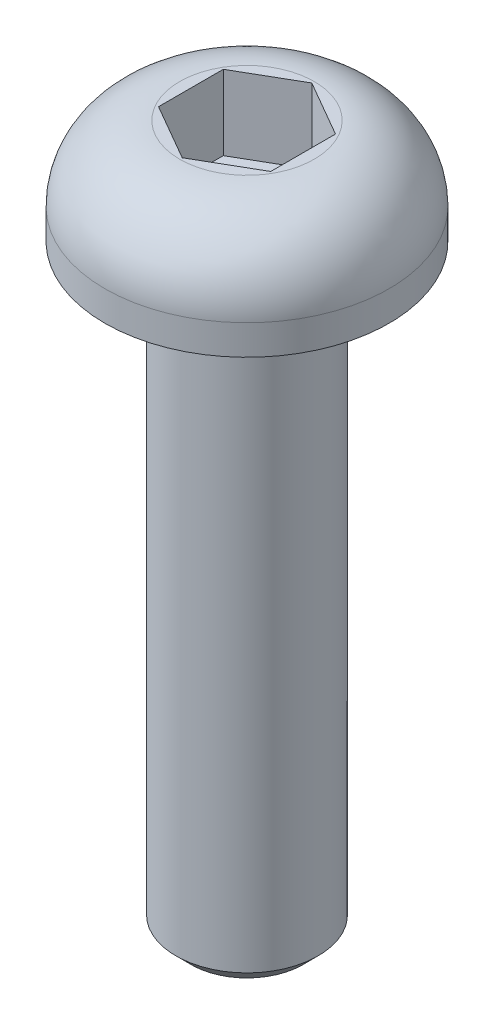
from build123d import *

# Parameters (mm, degrees)
SKETCH_1_R          = 1.9
EXTRUDE_1_DEPTH     = 1.4
CUT_EXTRUDE_1_DEPTH = 1
FILLET_1_R          = 1
SKETCH_3_R          = 0.95
EXTRUDE_2_DEPTH     = 8
CHAMFER_1_SIZE      = 0.2


with BuildPart() as part:
    # 草图1 → 凸台-拉伸1 (new body)
    with BuildSketch(Plane(origin=(0, 0, 0), x_dir=(1, 0, 0), z_dir=(0, 1, 0))):
        Circle(SKETCH_1_R)
    extrude(amount=EXTRUDE_1_DEPTH)

    # 草图2 → 切除-拉伸1 (cut)
    with BuildSketch(Plane(origin=(0, 1.4, 0), x_dir=(1, 0, 0), z_dir=(0, 1, 0))):
        Polygon((0, -0.866025404), (0.75, -0.433012702), (0.75, 0.433012702), (0, 0.866025404), (-0.75, 0.433012702), (-0.75, -0.433012702), align=None)
    extrude(amount=-CUT_EXTRUDE_1_DEPTH, mode=Mode.SUBTRACT)

    # 圆角1
    fillet_1_edges = [part.edges().sort_by_distance(p)[0] for p in [
        (-1.9, 1.4, 0),
    ]]
    fillet(fillet_1_edges, radius=FILLET_1_R)

    # 草图3 → 凸台-拉伸2 (add)
    with BuildSketch(Plane.XZ):
        Circle(SKETCH_3_R)
    extrude(amount=EXTRUDE_2_DEPTH)

    # 倒角1
    chamfer_1_edges = [part.edges().sort_by_distance(p)[0] for p in [
        (-0.95, -8, 0),
    ]]
    chamfer(chamfer_1_edges, length=CHAMFER_1_SIZE)


solid = part.part
